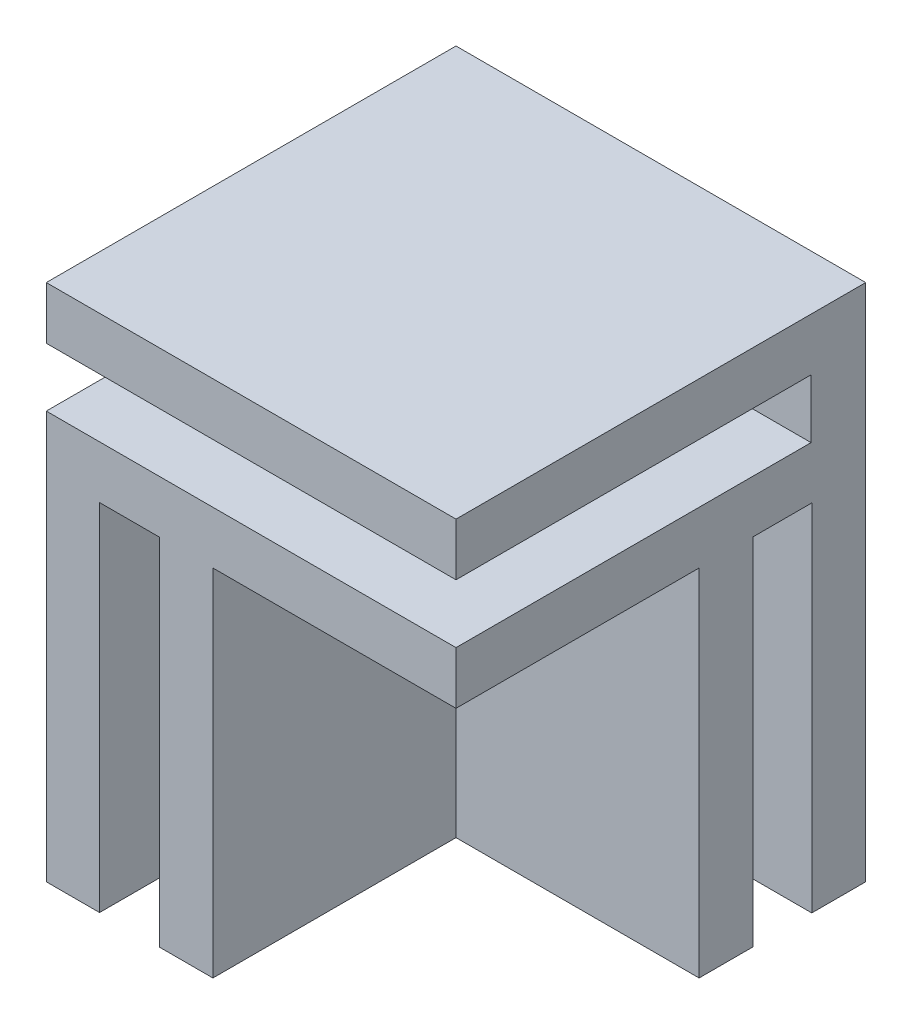
from build123d import *

# Parameters (mm, degrees)
ESQUISSE1_W             = 30
ESQUISSE1_H             = 30
BOSS_EXTRU_1_DEPTH      = 38
ESQUISSE2_W             = 17.8
ESQUISSE2_H             = 4.3
ESQUISSE2_W_2           = 4.4
ESQUISSE2_H_2           = 17.8
ENL_V_MAT_EXTRU_1_DEPTH = 26
ESQUISSE5_W             = 26
ESQUISSE5_H             = 4.3
ENL_V_MAT_EXTRU_4_DEPTH = 31


with BuildPart() as part:
    # Esquisse1 → Boss.-Extru.1 (new body)
    with BuildSketch(Plane(origin=(0, 0, 0), x_dir=(1, 0, 0), z_dir=(0, 1, 0))):
        with Locations((-20.886738322, -1.468531469)):
            Rectangle(ESQUISSE1_W, ESQUISSE1_H)
    extrude(amount=BOSS_EXTRU_1_DEPTH)

    # Esquisse2 → Enlèv. mat.-Extru.1 (cut)
    with BuildSketch(Plane.XZ):
        with Locations((-14.786738322, -7.431468531)):
            Rectangle(ESQUISSE2_W, ESQUISSE2_H)
        with Locations((-29.786738322, 7.568531469)):
            Rectangle(ESQUISSE2_W_2, ESQUISSE2_H_2)
        with Locations((-14.786738322, 7.568531469)):
            Rectangle(ESQUISSE2_W, ESQUISSE2_H_2)
    extrude(amount=-ENL_V_MAT_EXTRU_1_DEPTH, mode=Mode.SUBTRACT)

    # Esquisse5 → Enlèv. mat.-Extru.4 (cut, through all)
    with BuildSketch(Plane.ZY.offset(35.886738322)):
        with Locations((3.468531469, 32)):
            Rectangle(ESQUISSE5_W, ESQUISSE5_H)
    extrude(amount=-ENL_V_MAT_EXTRU_4_DEPTH, mode=Mode.SUBTRACT)


solid = part.part
